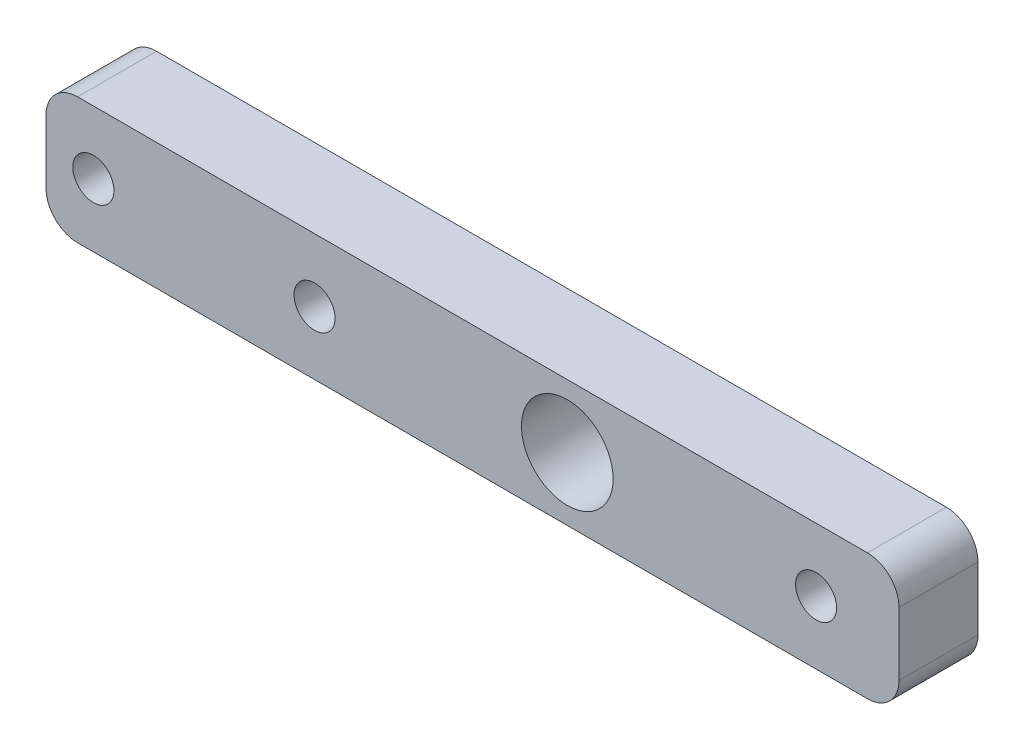
from build123d import *

# Parameters (mm, degrees)
DODANIE_WYCI_GNI_CIE1_DEPTH = 5
OTW_R_POD_RUB_M21_D         = 2.6
OTW_R_POD_RUB_M21_DEPTH     = 5
OTW_R_POD_RUB_M51_D         = 5.8
OTW_R_POD_RUB_M51_DEPTH     = 5
OTW_R_POD_RUB_M22_D         = 2.6
OTW_R_POD_RUB_M22_DEPTH     = 5


with BuildPart() as part:
    # Szkic1 → Dodanie-wyciągnięcie1 (new body)
    with BuildSketch(Plane.XY):
        with BuildLine():
            Line((-25, 4), (25, 4))
            ThreePointArc((25, 4), (26.414213562, 3.414213562), (27, 2))
            Line((27, 2), (27, -2))
            ThreePointArc((27, -2), (26.414213562, -3.414213562), (25, -4))
            Line((25, -4), (-25, -4))
            ThreePointArc((-25, -4), (-26.414213562, -3.414213562), (-27, -2))
            Line((-27, -2), (-27, 2))
            ThreePointArc((-27, 2), (-26.414213562, 3.414213562), (-25, 4))
        make_face()
    extrude(amount=DODANIE_WYCI_GNI_CIE1_DEPTH)

    # Otwór pod śrubę M21
    with Locations(Plane.XY.offset(5)):
        with Locations((-10, 0), (21.75, 0)):
            Hole(OTW_R_POD_RUB_M21_D / 2, depth=OTW_R_POD_RUB_M21_DEPTH)

    # Otwór pod śrubę M51
    with Locations(Plane.XY.offset(5)):
        with Locations((6, 0)):
            Hole(OTW_R_POD_RUB_M51_D / 2, depth=OTW_R_POD_RUB_M51_DEPTH)

    # Otwór pod śrubę M22
    with Locations(Plane.XY.offset(5)):
        with Locations((-24, 0)):
            Hole(OTW_R_POD_RUB_M22_D / 2, depth=OTW_R_POD_RUB_M22_DEPTH)


solid = part.part
